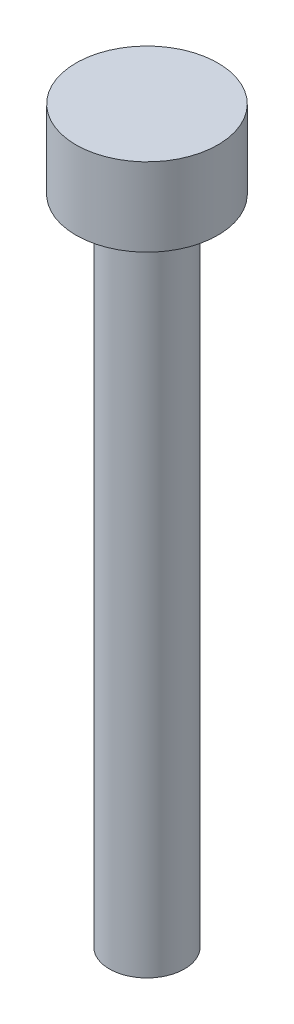
from build123d import *

# Parameters (mm, degrees)
SKETCH1_R           = 2.72
BOSS_EXTRUDE1_DEPTH = 3
SKETCH2_R           = 1.44
BOSS_EXTRUDE2_DEPTH = 25


with BuildPart() as part:
    # Sketch1 → Boss-Extrude1 (new body)
    with BuildSketch(Plane(origin=(0, 0, 0), x_dir=(1, 0, 0), z_dir=(0, 1, 0))):
        Circle(SKETCH1_R)
    extrude(amount=BOSS_EXTRUDE1_DEPTH)

    # Sketch2 → Boss-Extrude2 (add)
    with BuildSketch(Plane.XZ):
        Circle(SKETCH2_R)
    extrude(amount=BOSS_EXTRUDE2_DEPTH)


solid = part.part
